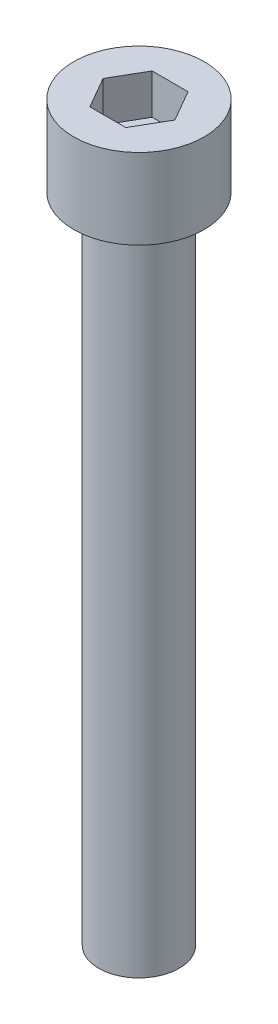
from build123d import *

# Parameters (mm, degrees)
SKETCH_1_R            = 6.5
EXTRUDE_248_DEPTH     = 8
CUT_EXTRUDE_382_DEPTH = 4
SKETCH_3_R            = 4
EXTRUDE_487_DEPTH     = 65


with BuildPart() as part:
    # 草图1 → Extrude 248 (new body)
    with BuildSketch(Plane(origin=(0, 0, 0), x_dir=(1, 0, 0), z_dir=(0, 1, 0))):
        Circle(SKETCH_1_R)
    extrude(amount=EXTRUDE_248_DEPTH)

    # 草图2 → Cut-Extrude 382 (cut)
    with BuildSketch(Plane(origin=(0, 8, 0), x_dir=(1, 0, 0), z_dir=(0, 1, 0))):
        Polygon((3.579571669, 0), (1.789785834, 3.1), (-1.789785834, 3.1), (-3.579571669, 0), (-1.789785834, -3.1), (1.789785834, -3.1), align=None)
    extrude(amount=-CUT_EXTRUDE_382_DEPTH, mode=Mode.SUBTRACT)

    # 草图3 → Extrude 487 (add)
    with BuildSketch(Plane.XZ):
        Circle(SKETCH_3_R)
    extrude(amount=EXTRUDE_487_DEPTH)


solid = part.part
